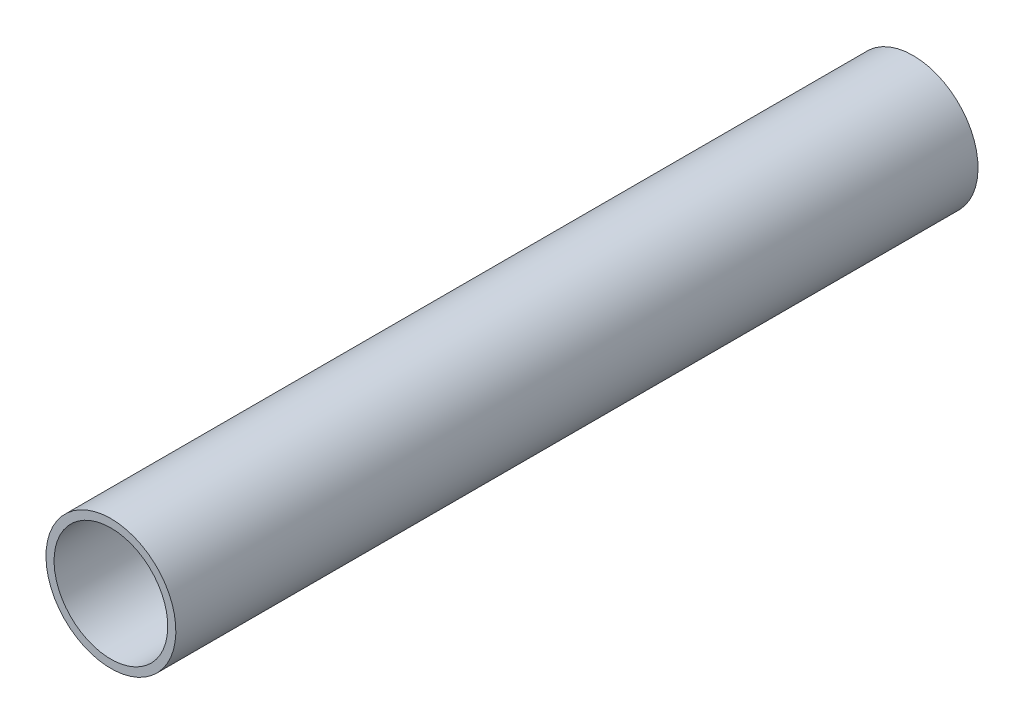
from build123d import *

# Parameters (mm, degrees)
SKETCH2_W = 2000
SKETCH2_H = 20.193


with BuildPart() as part:
    # Sketch2 → Revolve1 (revolve)
    with BuildSketch(Plane(origin=(0, 0, 0), x_dir=(0, 0, -1), z_dir=(1, 0, 0))):
        with Locations((0, 151.8285)):
            Rectangle(SKETCH2_W, SKETCH2_H)
    revolve(axis=Axis((0, 0, -17.970111657), (0, 0, 1)))


solid = part.part
